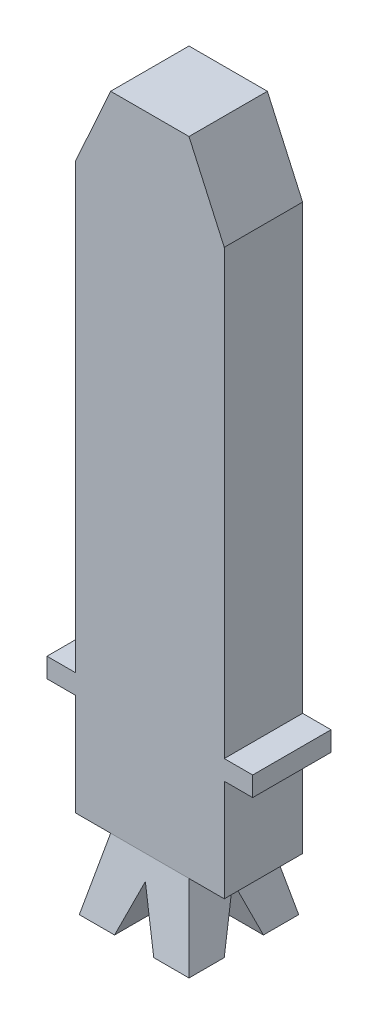
from build123d import *

# Parameters (mm, degrees)
BOSS_EXTRUDE1_DEPTH     = 2
SKETCH2_W               = 2
SKETCH2_H               = 2
SKETCH3_W               = 2.8
SKETCH3_H               = 2.8
CUT_EXTRUDE1_DEPTH      = 1.6000001
CUT_EXTRUDE1_DEPTH_BACK = 3.2000001
CUT_EXTRUDE2_DEPTH      = 5.425
CUT_EXTRUDE2_DEPTH_BACK = 1.825


with BuildPart() as part:
    # Sketch1 → Boss-Extrude1 (new body)
    with BuildSketch(Plane.XY):
        Polygon((1.9, 0), (2.625, 0), (2.625, -0.5), (1.9, -0.5), (1.9, -3.1), (-1.9, -3.1), (-1.9, -0.5), (-2.625, -0.5), (-2.625, 0), (-1.9, 0), (-1.9, 11.3), (-1, 13.3), (1, 13.3), (1.9, 11.3), align=None)
    extrude(amount=BOSS_EXTRUDE1_DEPTH)


with BuildPart() as body_2:
    # Sketch2 → Loft1 section 0
    with BuildSketch(Plane.XZ.offset(3.1)):
        with Locations((0, 1)):
            Rectangle(SKETCH2_W, SKETCH2_H)
    # Sketch3 → Loft1 section 1
    with BuildSketch(Plane(origin=(0, -4.9, 0), x_dir=(-1, 0, 0), z_dir=(0, -1, 0))):
        with Locations((0, -1)):
            Rectangle(SKETCH3_W, SKETCH3_H)
    loft()

    # Sketch4 → Cut-Extrude1 (cut, two sides)
    with BuildSketch(Plane.XY.offset(1.8)) as cut_extrude1_sk:
        Polygon((0, -3.611513086), (-0.5, -4.9), (0.5, -4.9), align=None)
    extrude(amount=CUT_EXTRUDE1_DEPTH, mode=Mode.SUBTRACT)
    extrude(cut_extrude1_sk.sketch, amount=-CUT_EXTRUDE1_DEPTH_BACK, mode=Mode.SUBTRACT)

    # Sketch5 → Cut-Extrude2 (cut, two sides)
    with BuildSketch(Plane(origin=(1.8, 0, -1.8), x_dir=(0, 0, 1), z_dir=(-1, 0, 0))) as cut_extrude2_sk:
        Polygon((2.8, -3.611513086), (2.3, -4.9), (3.3, -4.9), align=None)
    extrude(amount=CUT_EXTRUDE2_DEPTH, mode=Mode.SUBTRACT)
    extrude(cut_extrude2_sk.sketch, amount=-CUT_EXTRUDE2_DEPTH_BACK, mode=Mode.SUBTRACT)


solid = Compound([part.part, body_2.part])
